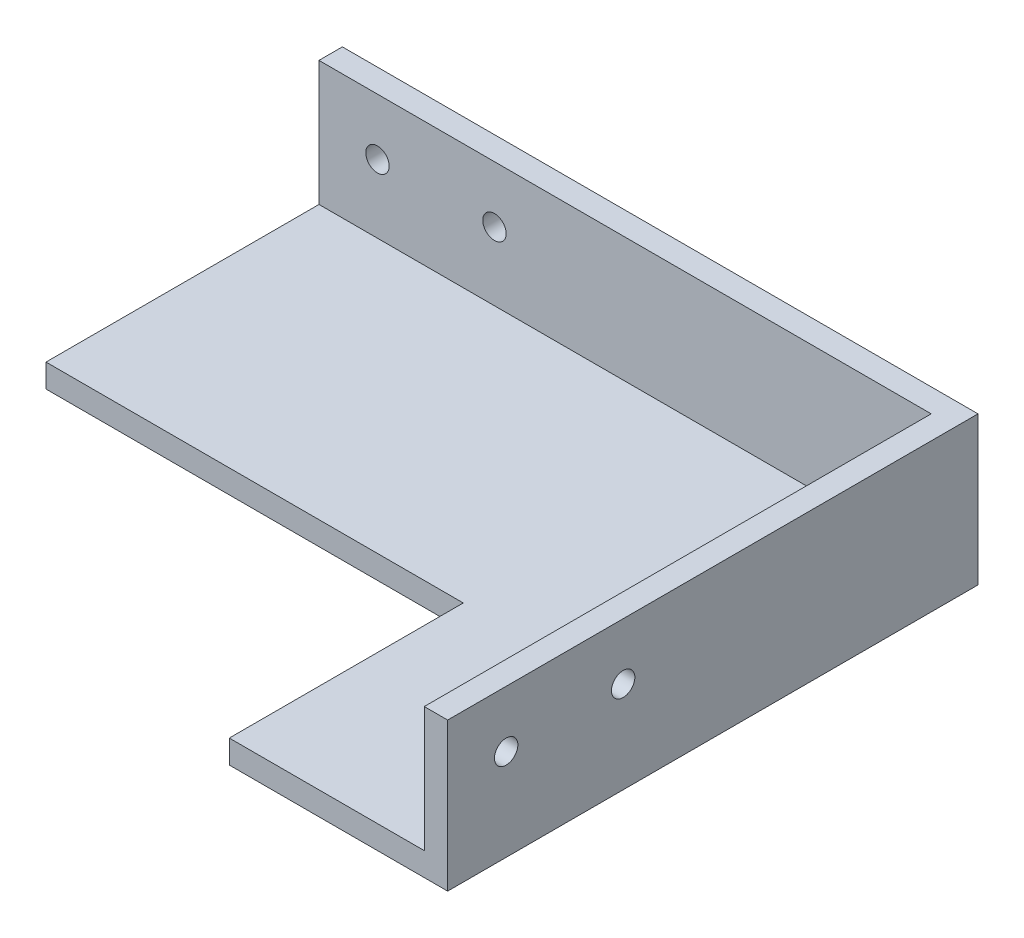
from build123d import *

# Parameters (mm, degrees)
SALIENTE_EXTRUIR1_DEPTH = 3
CROQUIS2_W              = 65
CROQUIS2_H              = 19
SALIENTE_EXTRUIR2_DEPTH = 3
CROQUIS3_W              = 81.5
CROQUIS3_H              = 19
SALIENTE_EXTRUIR3_DEPTH = 3
CROQUIS4_R              = 1.5
CORTAR_EXTRUIR1_DEPTH   = 69
CROQUIS5_R              = 1.5
CORTAR_EXTRUIR2_DEPTH   = 82.5


with BuildPart() as part:
    # Croquis1 → Saliente-Extruir1 (new body)
    with BuildSketch(Plane(origin=(0, 0, 0), x_dir=(1, 0, 0), z_dir=(0, 1, 0))):
        Polygon((-39.25, -2.5), (14.25, -2.5), (14.25, -32.5), (39.25, -32.5), (39.25, 32.5), (-39.25, 32.5), align=None)
    extrude(amount=SALIENTE_EXTRUIR1_DEPTH)

    # Croquis2 → Saliente-Extruir2 (add)
    with BuildSketch(Plane(origin=(39.25, 0, 0), x_dir=(0, 0, -1), z_dir=(1, 0, 0))):
        with Locations((0, 9.5)):
            Rectangle(CROQUIS2_W, CROQUIS2_H)
    extrude(amount=SALIENTE_EXTRUIR2_DEPTH)

    # Croquis3 → Saliente-Extruir3 (add)
    with BuildSketch(Plane(origin=(0, 0, -32.5), x_dir=(-1, 0, 0), z_dir=(0, 0, -1))):
        with Locations((-1.5, 9.5)):
            Rectangle(CROQUIS3_W, CROQUIS3_H)
    extrude(amount=SALIENTE_EXTRUIR3_DEPTH)

    # Croquis4 → Cortar-Extruir1 (cut, through all)
    with BuildSketch(Plane(origin=(0, 0, -35.5), x_dir=(-1, 0, 0), z_dir=(0, 0, -1))):
        with Locations((31.75, 11.75)):
            Circle(CROQUIS4_R)
        with Locations((16.75, 11.75)):
            Circle(CROQUIS4_R)
    extrude(amount=-CORTAR_EXTRUIR1_DEPTH, mode=Mode.SUBTRACT)

    # Croquis5 → Cortar-Extruir2 (cut, through all)
    with BuildSketch(Plane(origin=(42.25, 0, 0), x_dir=(0, 0, -1), z_dir=(1, 0, 0))):
        with Locations((-25, 11.75)):
            Circle(CROQUIS5_R)
        with Locations((-10, 11.75)):
            Circle(CROQUIS5_R)
    extrude(amount=-CORTAR_EXTRUIR2_DEPTH, mode=Mode.SUBTRACT)


solid = part.part
